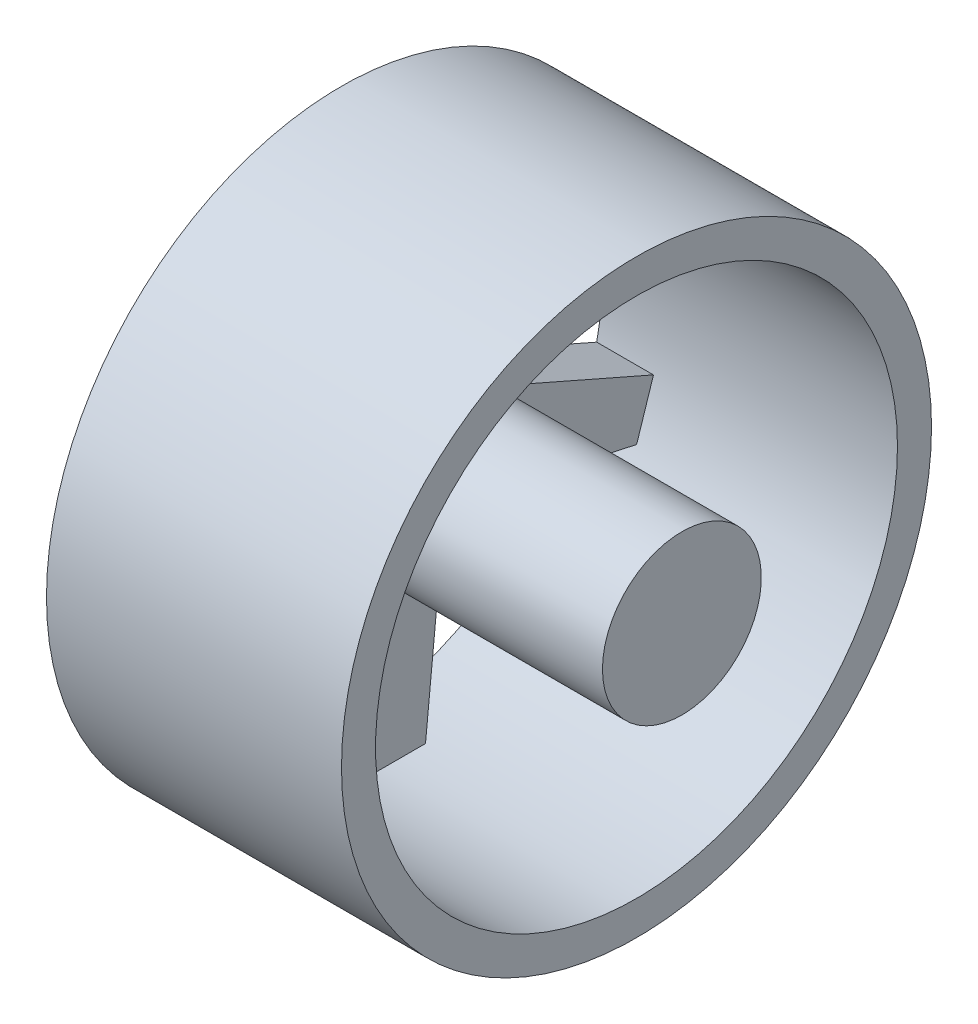
from build123d import *

# Parameters (mm, degrees)
SKETCH_2_R          = 26
SKETCH_2_R_2        = 23
EXTRUDE_1_DEPTH     = 26
SKETCH_4_R          = 7
EXTRUDE_1_2_DEPTH   = 30
EXTRUDE_2_DEPTH     = 5
SKETCH_7_R          = 6.5
CUT_EXTRUDE_1_DEPTH = 3


with BuildPart() as part:
    # Эскиз2 → Extrude 1 (new body)
    with BuildSketch(Plane(origin=(0, 0, 0), x_dir=(0, 0, -1), z_dir=(1, 0, 0))):
        Circle(SKETCH_2_R)
        Circle(SKETCH_2_R_2, mode=Mode.SUBTRACT)
    extrude(amount=EXTRUDE_1_DEPTH)


with BuildPart() as body_2:
    # Эскиз4 → Extrude 1 2 (new body)
    with BuildSketch(Plane.ZY):
        Circle(SKETCH_4_R)
    extrude(amount=-EXTRUDE_1_2_DEPTH)

    # Эскиз6 → Бобышка-Вытянуть2 (add)
    with BuildSketch(Plane.ZY):
        with BuildLine():
            ThreePointArc((-6.657395614, 2.163118961), (-4.114496766, 5.663118961), (0, 7))
            Line((0, 7), (-11.5, 19.918584287))
            Line((-11.5, 19.918584287), (-15.390003946, 17.092330986))
            Line((-15.390003946, 17.092330986), (-6.657395614, 2.163118961))
        make_face()
        with BuildLine():
            Line((11.5, 19.918584287), (0, 7))
            ThreePointArc((0, 7), (4.114496766, 5.663118961), (6.657395614, 2.163118961))
            Line((6.657395614, 2.163118961), (15.390003946, 17.092330986))
            Line((15.390003946, 17.092330986), (11.5, 19.918584287))
        make_face()
        with BuildLine():
            Line((22.497394817, -4.781968889), (6.657395614, 2.163118961))
            ThreePointArc((6.657395614, 2.163118961), (6.913818384, 1.095041255), (7, 0))
            ThreePointArc((7, 0), (6.237045669, -3.177933498), (4.114496766, -5.663118961))
            Line((4.114496766, -5.663118961), (21.011545526, -9.354942791))
            Line((21.011545526, -9.354942791), (22.497394817, -4.781968889))
        make_face()
        with BuildLine():
            ThreePointArc((4.114496766, -5.663118961), (0, -7), (-4.114496766, -5.663118961))
            Line((-4.114496766, -5.663118961), (-2.404154655, -22.874003593))
            Line((-2.404154655, -22.874003593), (2.404154655, -22.874003593))
            Line((2.404154655, -22.874003593), (4.114496766, -5.663118961))
        make_face()
        with BuildLine():
            ThreePointArc((-4.114496766, -5.663118961), (-6.657395614, -2.163118961), (-6.657395614, 2.163118961))
            Line((-6.657395614, 2.163118961), (-22.497394817, -4.781968889))
            Line((-22.497394817, -4.781968889), (-21.011545526, -9.354942791))
            Line((-21.011545526, -9.354942791), (-4.114496766, -5.663118961))
        make_face()
    extrude(amount=-EXTRUDE_2_DEPTH)

    # Эскиз7 → Вырез-Вытянуть1 (cut)
    with BuildSketch(Plane.ZY):
        Circle(SKETCH_7_R)
    extrude(amount=-CUT_EXTRUDE_1_DEPTH, mode=Mode.SUBTRACT)


solid = Compound([part.part, body_2.part])
